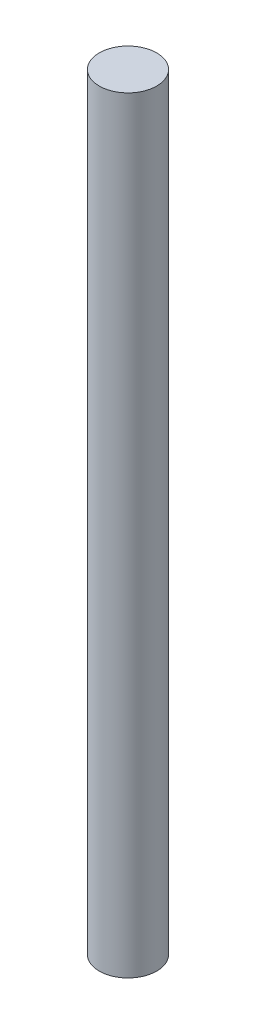
from build123d import *

# Parameters (mm, degrees)
SKETCH1_R           = 1.8034
BOSS_EXTRUDE1_DEPTH = 48.1076


with BuildPart() as part:
    # Sketch1 → Boss-Extrude1 (new body)
    with BuildSketch(Plane(origin=(0, 0, 0), x_dir=(1, 0, 0), z_dir=(0, 1, 0))):
        Circle(SKETCH1_R)
    extrude(amount=BOSS_EXTRUDE1_DEPTH)


solid = part.part
